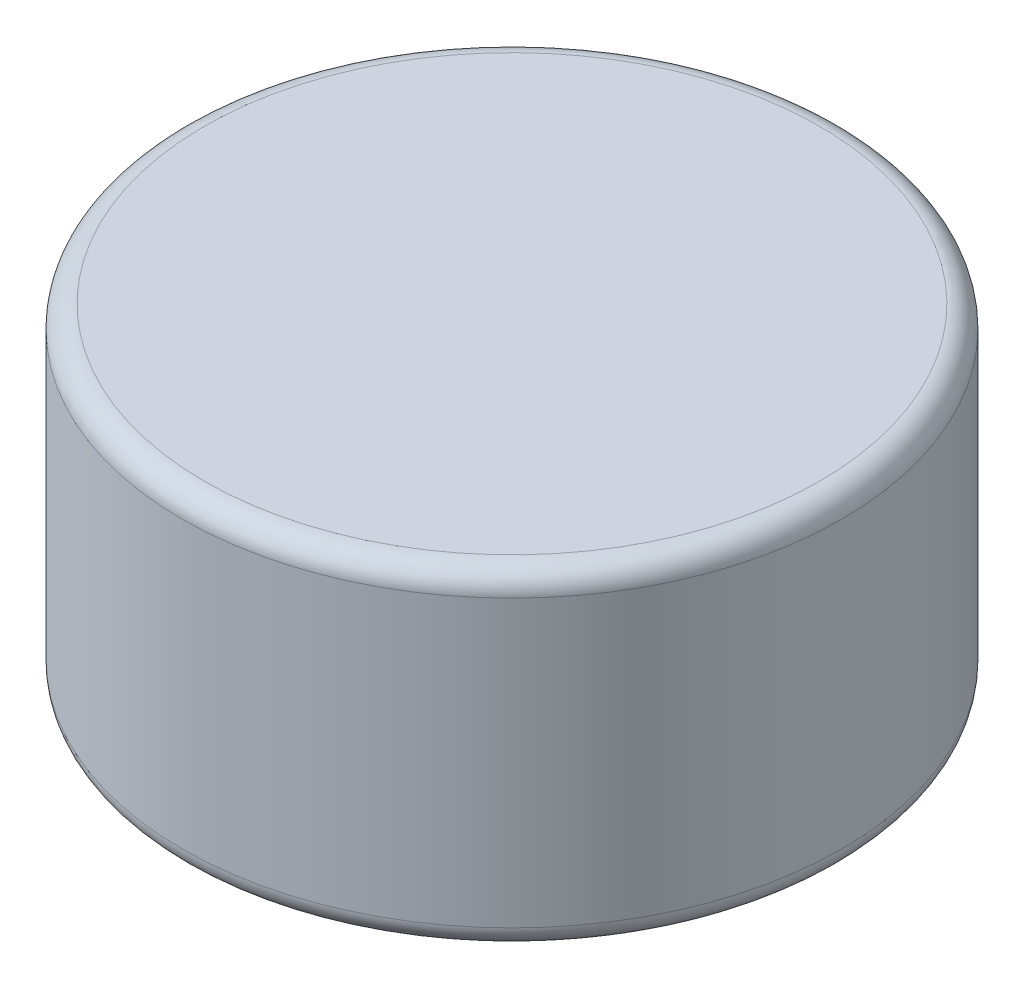
from build123d import *

# Parameters (mm, degrees)
SKETCH1_R           = 3
BOSS_EXTRUDE1_DEPTH = 1.5
FILLET1_R           = 0.2


with BuildPart() as part:
    # Sketch1 → Boss-Extrude1 (new body, symmetric)
    with BuildSketch(Plane(origin=(0, 0, 0), x_dir=(1, 0, 0), z_dir=(0, 1, 0))):
        Circle(SKETCH1_R)
    extrude(amount=BOSS_EXTRUDE1_DEPTH, both=True)

    # Fillet1
    fillet1_edges = [part.edges().sort_by_distance(p)[0] for p in [
        (-3, -1.5, 0),
        (-3, 1.5, 0),
    ]]
    fillet(fillet1_edges, radius=FILLET1_R)


solid = part.part
